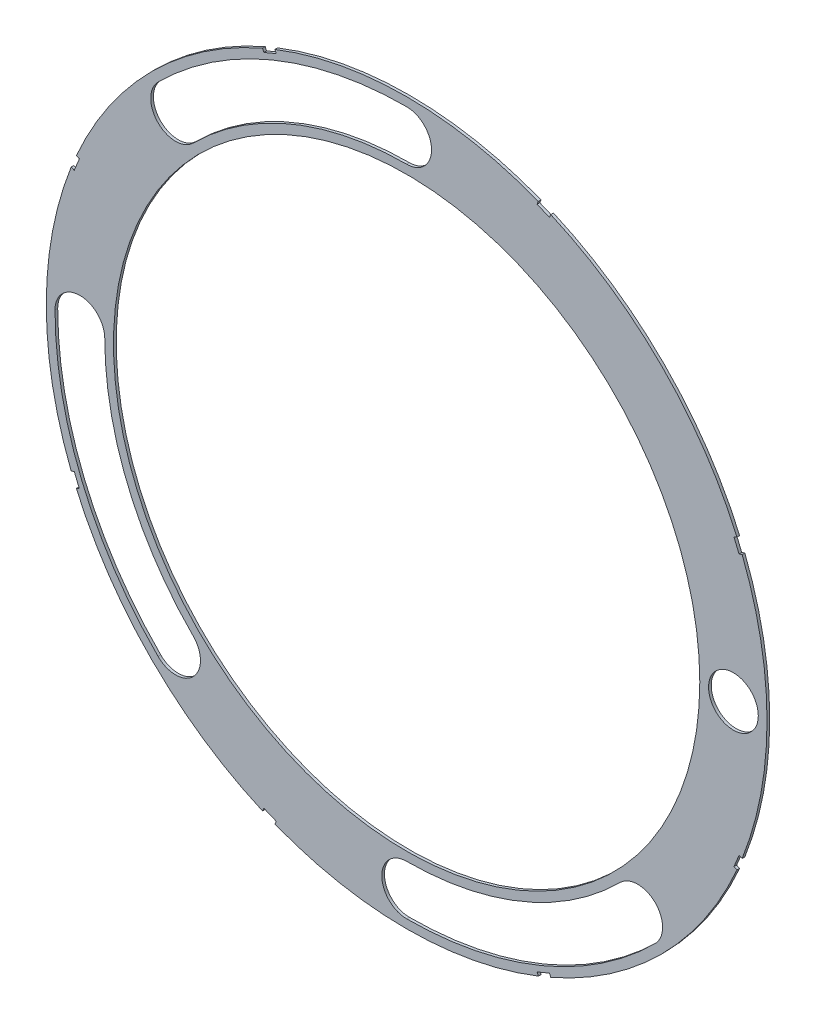
from build123d import *

# Parameters (mm, degrees)
SKETCH4_R           = 68.072
BOSS_EXTRUDE2_DEPTH = 0.508
SKETCH5_R           = 55.372
CUT_EXTRUDE5_DEPTH  = 1.508
SKETCH6_R           = 4.699
CUT_EXTRUDE6_DEPTH  = 1.508
CUT_EXTRUDE11_DEPTH = 1.508


with BuildPart() as part:
    # Sketch4 → Boss-Extrude2 (new body)
    with BuildSketch(Plane.XY):
        Circle(SKETCH4_R)
    extrude(amount=BOSS_EXTRUDE2_DEPTH)

    # Sketch5 → Cut-Extrude5 (cut, through all)
    with BuildSketch(Plane.XY.offset(0.508)):
        Circle(SKETCH5_R)
    extrude(amount=-CUT_EXTRUDE5_DEPTH, mode=Mode.SUBTRACT)

    # Sketch6 → Cut-Extrude6 (cut, through all)
    with BuildSketch(Plane.XY.offset(0.508)):
        with Locations((61.722, 0)):
            Circle(SKETCH6_R)
        with BuildLine():
            ThreePointArc((46.966739403, -46.966739623), (46.966739521, -40.321349991), (40.321349889, -40.321350078))
            ThreePointArc((40.321349889, -40.321350078), (21.821757973, -52.68238233), (1.451e-06, -57.023))
            ThreePointArc((1.451e-06, -57.023), (-4.699, -61.72200012), (1.691e-06, -66.421))
            ThreePointArc((1.691e-06, -66.421), (25.41821697, -61.365002135), (46.966739403, -46.966739623))
        make_face()
        with BuildLine():
            ThreePointArc((-46.966739623, -46.966739403), (-40.321349991, -46.966739521), (-40.321350078, -40.321349889))
            ThreePointArc((-40.321350078, -40.321349889), (-52.68238233, -21.821757973), (-57.023, -1.451e-06))
            ThreePointArc((-57.023, -1.451e-06), (-61.72200012, 4.699), (-66.421, -1.69e-06))
            ThreePointArc((-66.421, -1.69e-06), (-61.365002135, -25.41821697), (-46.966739623, -46.966739403))
        make_face()
        with BuildLine():
            ThreePointArc((-46.966739403, 46.966739623), (-46.966739521, 40.321349991), (-40.321349889, 40.321350078))
            ThreePointArc((-40.321349889, 40.321350078), (-21.821757973, 52.68238233), (-1.451e-06, 57.023))
            ThreePointArc((-1.451e-06, 57.023), (4.699, 61.72200012), (-1.69e-06, 66.421))
            ThreePointArc((-1.69e-06, 66.421), (-25.41821697, 61.365002135), (-46.966739403, 46.966739623))
        make_face()
    extrude(amount=-CUT_EXTRUDE6_DEPTH, mode=Mode.SUBTRACT)

    # Sketch8 → Cut-Extrude11 (cut, through all)
    with BuildSketch(Plane.XY.offset(0.508)):
        Polygon((63.962998999, 25.119703581), (62.990983081, 27.466357594), (61.817656075, 26.980349635), (62.789671993, 24.633695622), align=None)
        Polygon((-25.119703581, 63.962998999), (-27.466357594, 62.990983081), (-26.980349635, 61.817656075), (-24.633695622, 62.789671993), align=None)
        Polygon((-62.990983081, 27.466357594), (-63.962998999, 25.119703581), (-62.789671993, 24.633695622), (-61.817656075, 26.980349635), align=None)
        Polygon((-63.962998999, -25.119703581), (-62.990983081, -27.466357594), (-61.817656075, -26.980349635), (-62.789671993, -24.633695622), align=None)
        Polygon((-27.466357594, -62.990983081), (-25.119703581, -63.962998999), (-24.633695622, -62.789671993), (-26.980349635, -61.817656075), align=None)
        Polygon((25.119703581, -63.962998999), (27.466357594, -62.990983081), (26.980349635, -61.817656075), (24.633695622, -62.789671993), align=None)
        Polygon((62.990983081, -27.466357594), (63.962998999, -25.119703581), (62.789671993, -24.633695622), (61.817656075, -26.980349635), align=None)
        Polygon((27.466357594, 62.990983081), (25.119703581, 63.962998999), (24.633695622, 62.789671993), (26.980349635, 61.817656075), align=None)
    extrude(amount=-CUT_EXTRUDE11_DEPTH, mode=Mode.SUBTRACT)


solid = part.part
